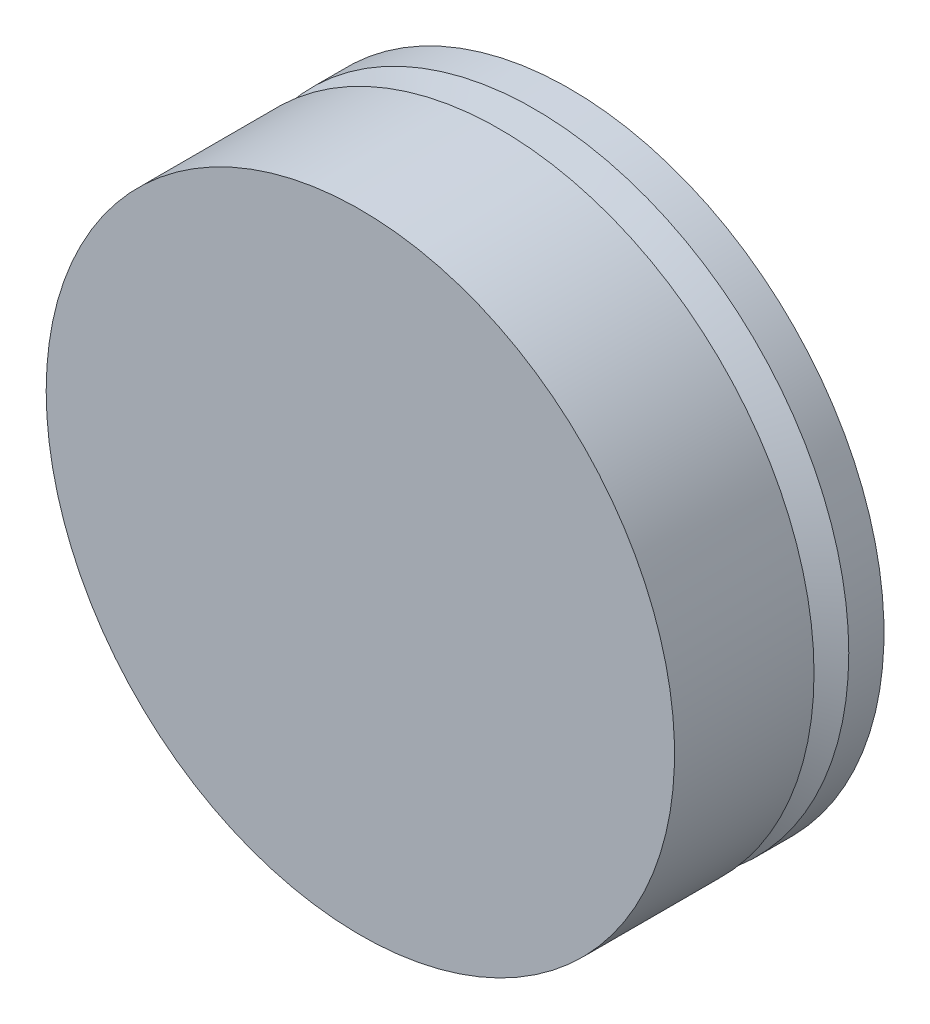
from build123d import *

# Parameters (mm, degrees)
SKETCH1_W           = 12
SKETCH1_H           = 4
BOSS_EXTRUDE1_DEPTH = 12
SKETCH2_OUTSIDE_W   = 17.488
SKETCH2_OUTSIDE_H   = 17.488
SKETCH2_OUTSIDE_R   = 6
CUT_EXTRUDE1_DEPTH  = 12


with BuildPart() as part:
    # Sketch1 → Boss-Extrude1 (new body)
    with BuildSketch(Plane(origin=(0, 0, 0), x_dir=(1, 0, 0), z_dir=(0, 1, 0))):
        Rectangle(SKETCH1_W, SKETCH1_H)
    extrude(amount=BOSS_EXTRUDE1_DEPTH)

    # Sketch2 outside → Cut-Extrude1 (cut)
    with BuildSketch(Plane(origin=(0, 0, -2), x_dir=(-1, 0, 0), z_dir=(0, 0, -1))):
        with Locations((0, 6)):
            Rectangle(SKETCH2_OUTSIDE_W, SKETCH2_OUTSIDE_H)
        with Locations((0, 6)):
            Circle(SKETCH2_OUTSIDE_R, mode=Mode.SUBTRACT)
    extrude(amount=-CUT_EXTRUDE1_DEPTH, mode=Mode.SUBTRACT)

    # Sketch5 → Cut-Revolve1 (revolve, cut)
    with BuildSketch(Plane(origin=(0, 0, 0), x_dir=(0, 0, -1), z_dir=(1, 0, 0))):
        Polygon((0.663673358, 10.775), (1.327346716, 12), (0.663673358, 12), align=None)
    revolve(axis=Axis((0, 6, 0), (0, 0, -1)), mode=Mode.SUBTRACT)


solid = part.part
